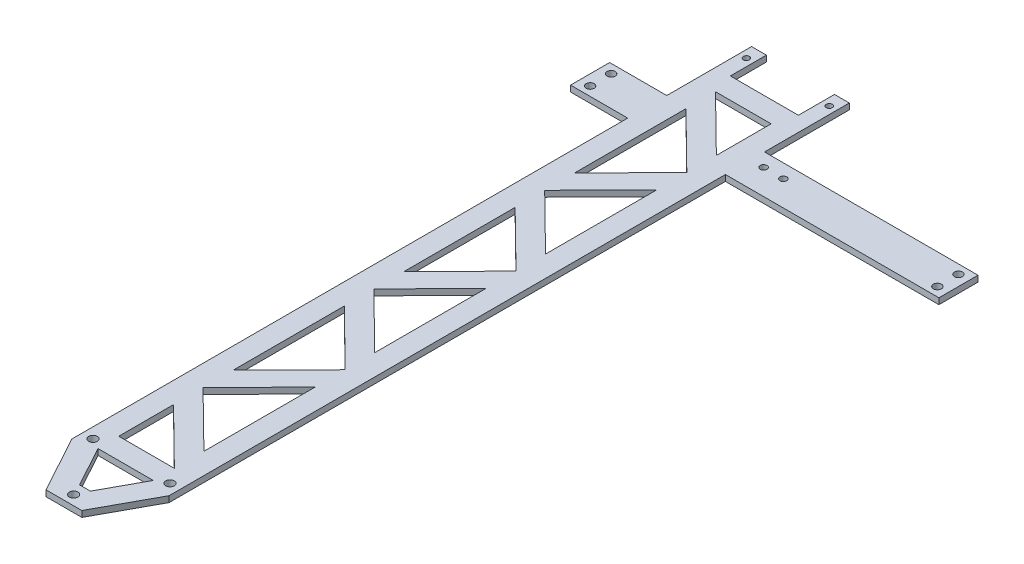
from build123d import *

# Parameters (mm, degrees)
SKETCH1_R           = 1.44
SKETCH1_R_2         = 1.35
SKETCH1_R_3         = 1
SKETCH1_R_4         = 1.125
BOSS_EXTRUDE1_DEPTH = 2


with BuildPart() as part:
    # Sketch1 → Boss-Extrude1 (new body)
    with BuildSketch(Plane(origin=(0, 0, 0), x_dir=(1, 0, 0), z_dir=(0, 1, 0))):
        Polygon((-17.332807681, 117.69771489), (-17.332807681, -38.346866508), (-6.997005855, -57.284094596), (4.918028523, -57.284094596), (15.167192319, -38.486712582), (15.167192319, 146.492065716), (86.167192319, 146.492065716), (86.167192319, 159.492065716), (15.167192319, 159.492065716), (15.167192319, 187.692065716), (10.237192319, 187.692065716), (10.237192319, 175.692065716), (-12.402807681, 175.692065716), (-12.402807681, 187.692065716), (-17.332807681, 187.692065716), (-17.332807681, 159.492065716), (-36.332807681, 159.492065716), (-36.332807681, 146.492065716), (-17.332807681, 146.492065716), align=None)
        with Locations((-13.842807681, -34.799722329)):
            Circle(SKETCH1_R, mode=Mode.SUBTRACT)
        with Locations((-1.042807681, -54.059722329)):
            Circle(SKETCH1_R, mode=Mode.SUBTRACT)
        Polygon((-2.842807681, -50.284094596), (-10.225590468, -36.757379986), (8.137192319, -36.757379986), (0.761829434, -50.284094596), align=None, mode=Mode.SUBTRACT)
        with Locations((11.757192319, -34.799722329)):
            Circle(SKETCH1_R, mode=Mode.SUBTRACT)
        Polygon((8.167192319, -29.757379986), (-10.332807681, -29.757379986), (-10.332807681, -11.546628322), align=None, mode=Mode.SUBTRACT)
        Polygon((8.167192319, -19.934969699), (-10.332807681, -1.724218034), (8.167192319, 17.069624543), align=None, mode=Mode.SUBTRACT)
        Polygon((8.167192319, 27.048047931), (-10.332807681, 8.254205353), (-10.332807681, 45.258799595), align=None, mode=Mode.SUBTRACT)
        Polygon((8.167192319, 36.870458218), (-10.332807681, 55.081209882), (8.167192319, 73.87505246), align=None, mode=Mode.SUBTRACT)
        Polygon((8.167192319, 83.853475847), (-10.332807681, 65.05963327), (-10.332807681, 102.064227512), align=None, mode=Mode.SUBTRACT)
        Polygon((8.167192319, 93.675886135), (-10.332807681, 111.886637799), (8.167192319, 130.680480377), align=None, mode=Mode.SUBTRACT)
        with Locations((-32.832807681, 149.492065716)):
            Circle(SKETCH1_R_2, mode=Mode.SUBTRACT)
        with Locations((-32.832807681, 156.492065716)):
            Circle(SKETCH1_R_2, mode=Mode.SUBTRACT)
        with Locations((-14.867807681, 183.496000094)):
            Circle(SKETCH1_R_3, mode=Mode.SUBTRACT)
        Polygon((8.167192319, 140.658903764), (-10.361742255, 121.835667033), (-10.361742255, 158.89813761), align=None, mode=Mode.SUBTRACT)
        with Locations((19.467192319, 154.892065716)):
            Circle(SKETCH1_R_4, mode=Mode.SUBTRACT)
        Polygon((8.167192319, 150.481314052), (-10.332807681, 168.692065716), (8.167192319, 168.692065716), align=None, mode=Mode.SUBTRACT)
        with Locations((12.702192319, 183.496000094)):
            Circle(SKETCH1_R_3, mode=Mode.SUBTRACT)
        with Locations((26.031178731, 154.892065716)):
            Circle(SKETCH1_R_4, mode=Mode.SUBTRACT)
        with Locations((82.667192319, 149.492065716)):
            Circle(SKETCH1_R_2, mode=Mode.SUBTRACT)
        with Locations((82.667192319, 156.492065716)):
            Circle(SKETCH1_R_2, mode=Mode.SUBTRACT)
    extrude(amount=BOSS_EXTRUDE1_DEPTH)


solid = part.part
